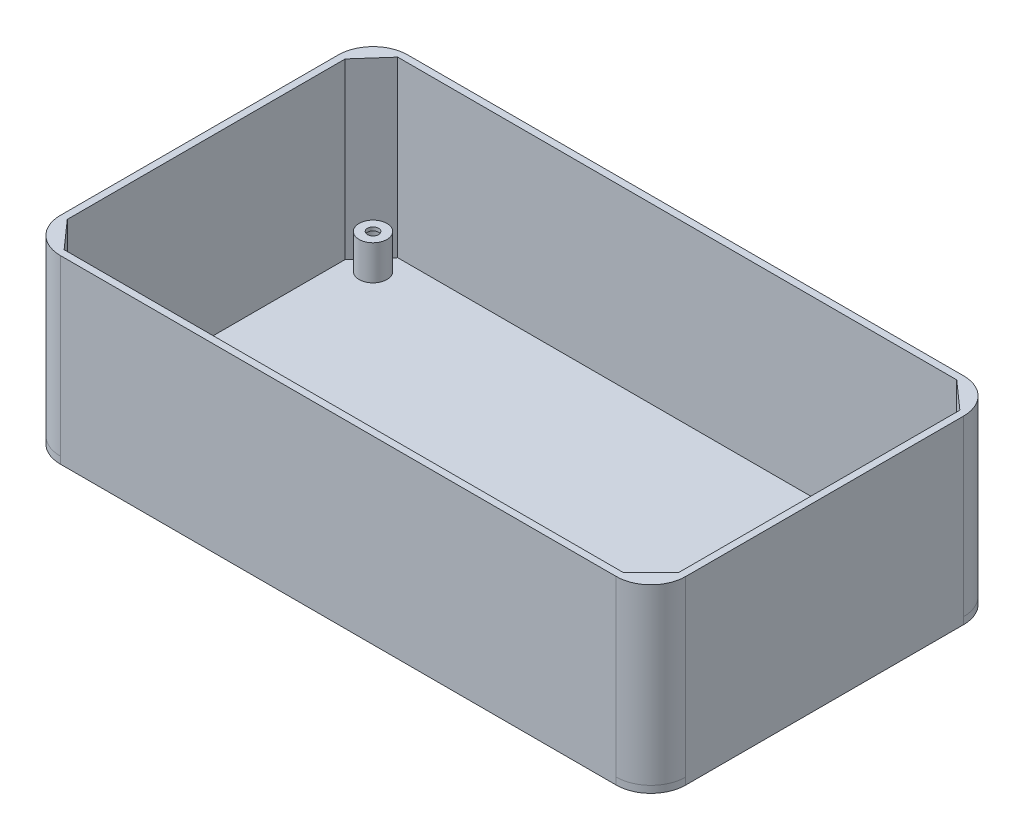
from build123d import *

# Parameters (mm, degrees)
SKETCH_1_W          = 180
SKETCH_1_H          = 100
EXTRUDE_1_DEPTH     = 2
FILLET_2_R          = 10
SKETCH_3_R          = 4
EXTRUDE_2_DEPTH     = 10
SKETCH_4_R          = 3
CUT_EXTRUDE_1_DEPTH = 11
SKETCH_5_R          = 1.6
CUT_EXTRUDE_2_DEPTH = 13
SKETCH_6_W          = 180
SKETCH_6_H          = 100
SKETCH_6_W_2        = 176
SKETCH_6_H_2        = 96
EXTRUDE_4_DEPTH     = 50
EXTRUDE_5_DEPTH     = 50
FILLET_4_R          = 10


with BuildPart() as part:
    # Эскиз1 → Бобышка-Вытянуть1 (new body)
    with BuildSketch(Plane(origin=(0, 0, 0), x_dir=(1, 0, 0), z_dir=(0, 1, 0))):
        with Locations((19.908592322, -3.436928702)):
            Rectangle(SKETCH_1_W, SKETCH_1_H)
    extrude(amount=EXTRUDE_1_DEPTH)

    # Скругление2
    fillet_2_edges = [part.edges().sort_by_distance(p)[0] for p in [
        (-70.091407678, 1, -46.563071298),
        (109.908592322, 1, -46.563071298),
        (109.908592322, 1, 53.436928702),
        (-70.091407678, 1, 53.436928702),
    ]]
    fillet(fillet_2_edges, radius=FILLET_2_R)

    # Эскиз3 → Бобышка-Вытянуть2 (add)
    with BuildSketch(Plane(origin=(0, 2, 0), x_dir=(1, 0, 0), z_dir=(0, 1, 0))):
        with Locations((-61.091407678, 37.563071298)):
            Circle(SKETCH_3_R)
        with Locations((100.908592322, 37.563071298)):
            Circle(SKETCH_3_R)
        with Locations((100.908592322, -44.436928702)):
            Circle(SKETCH_3_R)
        with Locations((-61.091407678, -44.436928702)):
            Circle(SKETCH_3_R)
    extrude(amount=EXTRUDE_2_DEPTH)

    # Эскиз4 → Вырез-Вытянуть1 (cut)
    with BuildSketch(Plane.XZ):
        with Locations((-61.091407678, -37.563071298)):
            Circle(SKETCH_4_R)
        with Locations((-61.091407678, 44.436928702)):
            Circle(SKETCH_4_R)
        with Locations((100.908592322, 44.436928702)):
            Circle(SKETCH_4_R)
        with Locations((100.908592322, -37.563071298)):
            Circle(SKETCH_4_R)
    extrude(amount=-CUT_EXTRUDE_1_DEPTH, mode=Mode.SUBTRACT)

    # Эскиз5 → Вырез-Вытянуть2 (cut, through all)
    with BuildSketch(Plane(origin=(0, 12, 0), x_dir=(1, 0, 0), z_dir=(0, 1, 0))):
        with Locations((100.908592322, 37.563071298)):
            Circle(SKETCH_5_R)
        with Locations((100.908592322, -44.436928702)):
            Circle(SKETCH_5_R)
        with Locations((-61.091407678, 37.563071298)):
            Circle(SKETCH_5_R)
        with Locations((-61.091407678, -44.436928702)):
            Circle(SKETCH_5_R)
    extrude(amount=-CUT_EXTRUDE_2_DEPTH, mode=Mode.SUBTRACT)

    # Эскиз6 → Бобышка-Вытянуть4 (add)
    with BuildSketch(Plane(origin=(0, 2, 0), x_dir=(1, 0, 0), z_dir=(0, 1, 0))):
        with Locations((19.908592322, -3.436928702)):
            Rectangle(SKETCH_6_W, SKETCH_6_H)
        with Locations((19.908592322, -3.436928702)):
            Rectangle(SKETCH_6_W_2, SKETCH_6_H_2, mode=Mode.SUBTRACT)
    extrude(amount=EXTRUDE_4_DEPTH)

    # Эскиз2 → Бобышка-Вытянуть5 (add)
    with BuildSketch(Plane(origin=(0, 2, 0), x_dir=(1, 0, 0), z_dir=(0, 1, 0))):
        Polygon((99.908592322, 46.563071298), (-60.091407678, 46.563071298), (-70.091407678, 46.563071298), (-70.091407678, 36.563071298), (-70.091407678, -43.436928702), (-70.091407678, -53.436928702), (-60.091407678, -53.436928702), (99.908592322, -53.436928702), (109.908592322, -53.436928702), (109.908592322, -43.436928702), (109.908592322, 36.563071298), (109.908592322, 46.563071298), align=None)
        Polygon((-68.091407678, -43.436928702), (-68.091407678, 36.563071298), (-60.987361381, 44.563071298), (99.908592322, 44.563071298), (107.908592322, 37.459025001), (107.908592322, -43.436928702), (99.908592322, -51.436928702), (-60.987361381, -51.436928702), align=None, mode=Mode.SUBTRACT)
    extrude(amount=EXTRUDE_5_DEPTH)

    # Скругление4
    fillet_4_edges = [part.edges().sort_by_distance(p)[0] for p in [
        (-70.091407678, 27, 53.436928702),
        (-70.091407678, 27, -46.563071298),
        (109.908592322, 27, -46.563071298),
        (109.908592322, 27, 53.436928702),
    ]]
    fillet(fillet_4_edges, radius=FILLET_4_R)


solid = part.part
